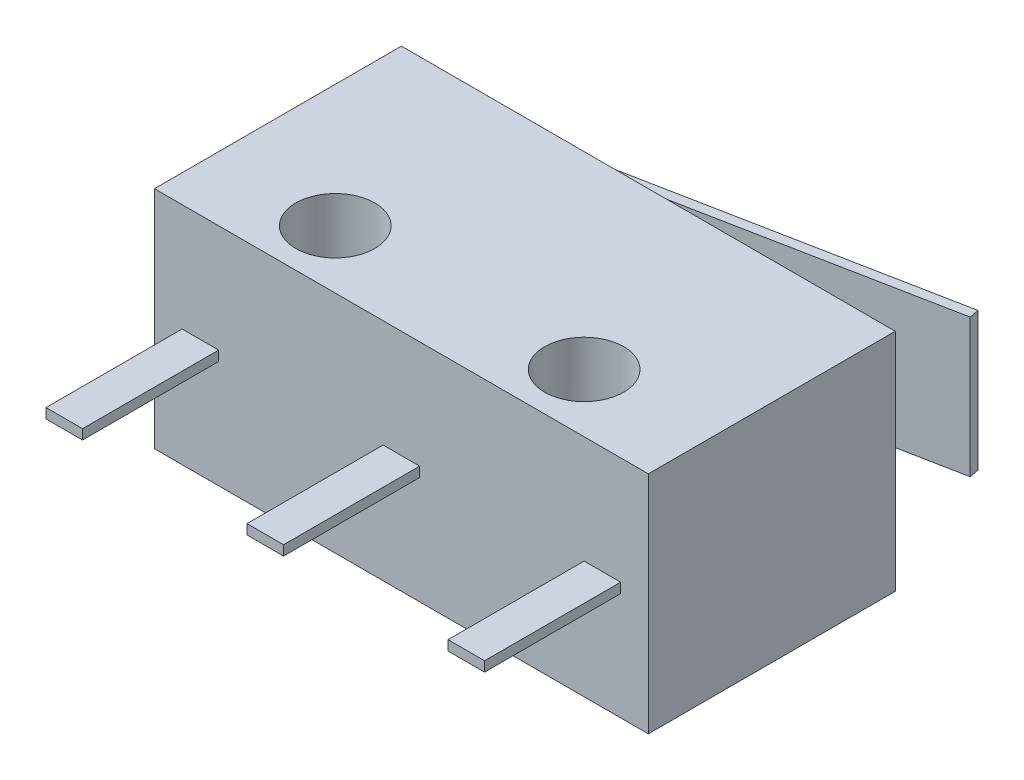
from build123d import *

# Parameters (mm, degrees)
SKETCH1_W           = 12.7
SKETCH1_H           = 6.35
BOSS_EXTRUDE1_DEPTH = 5.7912
SKETCH2_R           = 1.016
CUT_EXTRUDE1_DEPTH  = 5.7912
BOSS_EXTRUDE2_DEPTH = 3.556
SKETCH4_W           = 12.462950418
SKETCH4_H           = 3.556
BOSS_EXTRUDE3_DEPTH = 0.254
SKETCH5_W           = 0.9398
SKETCH5_H           = 0.254
BOSS_EXTRUDE4_DEPTH = 3.5


with BuildPart() as part:
    # Sketch1 → Boss-Extrude1 (new body)
    with BuildSketch(Plane(origin=(0, 0, 0), x_dir=(1, 0, 0), z_dir=(0, 1, 0))):
        Rectangle(SKETCH1_W, SKETCH1_H)
    extrude(amount=BOSS_EXTRUDE1_DEPTH)

    # Sketch2 → Cut-Extrude1 (cut)
    with BuildSketch(Plane(origin=(0, 5.7912, 0), x_dir=(1, 0, 0), z_dir=(0, 1, 0))):
        with Locations((3.2, -1.675)):
            Circle(SKETCH2_R)
        with Locations((-3.2, -1.675)):
            Circle(SKETCH2_R)
    extrude(amount=-CUT_EXTRUDE1_DEPTH, mode=Mode.SUBTRACT)

    # Sketch3 → Boss-Extrude2 (add)
    with BuildSketch(Plane(origin=(0, 4.6736, 0), x_dir=(1, 0, 0), z_dir=(0, 1, 0))):
        with BuildLine():
            Line((-3.1496, 3.175), (-1.6256, 3.175))
            ThreePointArc((-1.6256, 3.175), (-2.3876, 3.937), (-3.1496, 3.175))
        make_face()
    extrude(amount=-BOSS_EXTRUDE2_DEPTH)

    # Sketch5 → Boss-Extrude4 (add)
    with BuildSketch(Plane.XY.offset(3.175)):
        with Locations((-5.1689, 2.8956)):
            Rectangle(SKETCH5_W, SKETCH5_H)
        with Locations((0, 2.8956)):
            Rectangle(SKETCH5_W, SKETCH5_H)
        with Locations((5.1689, 2.8956)):
            Rectangle(SKETCH5_W, SKETCH5_H)
    extrude(amount=BOSS_EXTRUDE4_DEPTH)


with BuildPart() as body_2:
    # Sketch4 → Boss-Extrude3 (new body)
    with BuildSketch(Plane(origin=(-0.834017587, 0, -4.255941978), x_dir=(-0.981334679, 0, 0.192307692), z_dir=(-0.192307692, 0, -0.981334679))):
        with Locations((-0.610576923, 2.8956)):
            Rectangle(SKETCH4_W, SKETCH4_H)
    extrude(amount=BOSS_EXTRUDE3_DEPTH)


solid = Compound([part.part, body_2.part])
